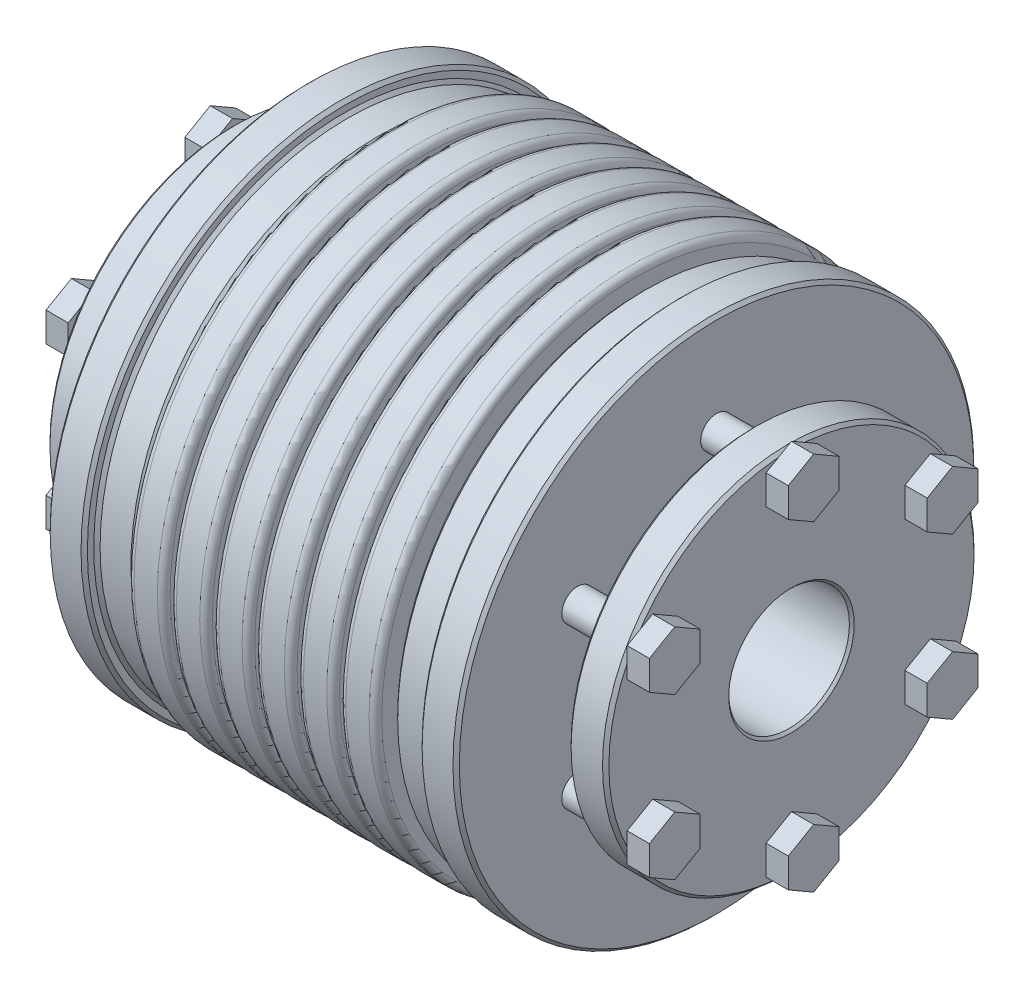
from build123d import *

# Parameters (mm, degrees)
SKETCH1_R                      = 41
BOSS_EXTRUDE1_DEPTH            = 44
SKETCH2_R                      = 9.5
CUT_EXTRUDE1_DEPTH             = 19
CHAMFER1_SIZE                  = 0.381
CUT_EXTRUDE2_REACH             = 46
SKETCH5_R                      = 25.4405
CUT_EXTRUDE2_DIRECTION_2_REACH = 46
SKETCH8_W                      = 1
SKETCH8_H                      = 13.5595
FILLET1_R                      = 1
FILLET2_R                      = 0.25
BOSS_EXTRUDE2_DEPTH            = 3.5
BOSS_EXTRUDE2_2_DEPTH          = 3.5
BOSS_EXTRUDE2_3_DEPTH          = 3.5
BOSS_EXTRUDE2_4_DEPTH          = 3.5
BOSS_EXTRUDE2_5_DEPTH          = 3.5
BOSS_EXTRUDE2_6_DEPTH          = 3.5
SKETCH11_R                     = 2.5
BOSS_EXTRUDE3_DEPTH            = 15.295142
CHAMFER2_SIZE                  = 0.5


with BuildPart() as part:
    # Sketch1 → Boss-Extrude1 (new body, symmetric)
    with BuildSketch(Plane(origin=(0, 0, 0), x_dir=(0, 0, -1), z_dir=(1, 0, 0))):
        Circle(SKETCH1_R)
    extrude(amount=BOSS_EXTRUDE1_DEPTH, both=True)

    # Sketch2 → Cut-Extrude1 (cut)
    with BuildSketch(Plane(origin=(44, 0, 0), x_dir=(0, 0, -1), z_dir=(1, 0, 0))):
        Circle(SKETCH2_R)
    cut_extrude1 = extrude(amount=-CUT_EXTRUDE1_DEPTH, mode=Mode.SUBTRACT)

    # Mirror3: Cut-Extrude1 across plane
    add(cut_extrude1.mirror(Plane(origin=(0, 0, 0), x_dir=(0, 0, 1), z_dir=(1, 0, 0))), mode=Mode.SUBTRACT)

    # Chamfer1
    chamfer1_edges = [part.edges().sort_by_distance(p)[0] for p in [
        (-44, 0, 41),
        (44, 0, 41),
        (44, 0, 9.5),
        (-44, 0, 9.5),
    ]]
    chamfer(chamfer1_edges, length=CHAMFER1_SIZE)

    # Cut-Extrude2: up to this face of the body (flat: up to its plane)
    cut_extrude2_end = Plane(part.part.faces().sort_by_distance((-25, 0, 0))[0])
    # Sketch5 → Cut-Extrude2 (cut, up to the picked face)
    with BuildSketch(Plane(origin=(0, 0, 0), x_dir=(0, 0, -1), z_dir=(1, 0, 0)), mode=Mode.PRIVATE) as cut_extrude2_sk1:
        Circle(SKETCH5_R)
    cut_extrude2_tool1 = split(extrude(cut_extrude2_sk1.sketch, amount=-CUT_EXTRUDE2_REACH, mode=Mode.PRIVATE), bisect_by=cut_extrude2_end, keep=Keep.BOTH, mode=Mode.PRIVATE)
    add(cut_extrude2_tool1.solids().sort_by(Axis((0, 0, 0), (-1, 0, 0)))[0], mode=Mode.SUBTRACT)

    # Cut-Extrude2 direction 2: up to this face of the body (flat: up to its plane)
    cut_extrude2_direction_2_end = Plane(part.part.faces().sort_by_distance((25, 0, 0))[0])
    # Sketch5 → Cut-Extrude2 direction 2 (cut, up to the picked face)
    with BuildSketch(Plane(origin=(0, 0, 0), x_dir=(0, 0, -1), z_dir=(1, 0, 0)), mode=Mode.PRIVATE) as cut_extrude2_direction_2_sk1:
        Circle(SKETCH5_R)
    cut_extrude2_direction_2_tool1 = split(extrude(cut_extrude2_direction_2_sk1.sketch, amount=CUT_EXTRUDE2_DIRECTION_2_REACH, mode=Mode.PRIVATE), bisect_by=cut_extrude2_direction_2_end, keep=Keep.BOTH, mode=Mode.PRIVATE)
    add(cut_extrude2_direction_2_tool1.solids().sort_by(Axis((0, 0, 0), (1, 0, 0)))[0], mode=Mode.SUBTRACT)

    # Sketch8 → Cut-Revolve1 (revolve, cut)
    with BuildSketch(Plane(origin=(0, 0, 0), x_dir=(1, 0, 0), z_dir=(0, 1, 0)), mode=Mode.PRIVATE) as cut_revolve1_sk:
        with Locations((0, 34.22025)):
            Rectangle(SKETCH8_W, SKETCH8_H)
        with Locations((6.666666667, 34.22025)):
            Rectangle(SKETCH8_W, SKETCH8_H)
        with Locations((13.333333333, 34.22025)):
            Rectangle(SKETCH8_W, SKETCH8_H)
        with Locations((20, 34.22025)):
            Rectangle(SKETCH8_W, SKETCH8_H)
    cut_revolve1 = revolve(cut_revolve1_sk.sketch.rotate(Axis((0, 0, 0), (1, 0, 0)), 180), axis=Axis((0, 0, 0), (1, 0, 0)), mode=Mode.SUBTRACT)  # turned: the seam where the file's is

    # Mirror2: Cut-Revolve1 across plane
    add(cut_revolve1.mirror(Plane(origin=(0, 0, 0), x_dir=(0, 0, 1), z_dir=(1, 0, 0))), mode=Mode.SUBTRACT)

    # Fillet1
    fillet1_edges = [part.edges().sort_by_distance(p)[0] for p in [
        (-0.5, 0, 41),
        (0.5, 0, 41),
        (19.5, 0, 41),
        (20.5, 0, 41),
        (6.166666667, 0, 41),
        (7.166666667, 0, 41),
        (12.833333333, 0, 41),
        (13.833333333, 0, 41),
        (-20.5, 0, 41),
        (-19.5, 0, 41),
        (-6.166666667, 0, 41),
        (-7.166666667, 0, 41),
        (-12.833333333, 0, 41),
        (-13.833333333, 0, 41),
    ]]
    fillet(fillet1_edges, radius=FILLET1_R)

    # Fillet2
    fillet2_edges = [part.edges().sort_by_distance(p)[0] for p in [
        (0.5, 0, -27.4405),
        (-0.5, 0, -27.4405),
        (20.5, 0, -27.4405),
        (19.5, 0, -27.4405),
        (7.166666667, 0, -27.4405),
        (6.166666667, 0, -27.4405),
        (13.833333333, 0, -27.4405),
        (12.833333333, 0, -27.4405),
        (-20.5, 0, -27.4405),
        (-19.5, 0, -27.4405),
        (-6.166666667, 0, -27.4405),
        (-7.166666667, 0, -27.4405),
        (-12.833333333, 0, -27.4405),
        (-13.833333333, 0, -27.4405),
    ]]
    fillet(fillet2_edges, radius=FILLET2_R)

    # Sketch9 → Cut-Revolve2 (revolve, cut)
    with BuildSketch(Plane.XY, mode=Mode.PRIVATE) as cut_revolve2_sk:
        Polygon((20.5, 39), (26.352429211, 39), (26.352429211, 41), (32.204858423, 41), (32.204858423, 20.218058827), (38.057287634, 21.25), (38.057287634, 29.25), (44, 29.25), (44, 46), (20.5, 46), align=None)
        Polygon((-20.5, 46), (-20.5, 39), (-26.352429211, 39), (-26.352429211, 41), (-32.204858423, 41), (-32.204858423, 20.218058827), (-38.057287634, 21.25), (-38.057287634, 29.25), (-44, 29.25), (-44, 46), align=None)
    revolve(cut_revolve2_sk.sketch.rotate(Axis((44, 0, 0), (-1, 0, 0)), 270), axis=Axis((44, 0, 0), (-1, 0, 0)), mode=Mode.SUBTRACT)  # turned: the seam where the file's is

    # Chamfer2
    chamfer2_edges = [part.edges().sort_by_distance(p)[0] for p in [
        (20.5, 0, -39),
        (26.352429211, 0, -39),
        (26.352429211, 0, 41),
        (32.204858423, 0, 41),
        (38.057287634, 0, -29.25),
        (44, 0, -29.25),
        (-38.057287634, 0, -29.25),
        (-44, 0, -29.25),
        (-20.5, 0, -39),
        (-26.352429211, 0, -39),
        (-26.352429211, 0, 41),
        (-32.204858423, 0, 41),
    ]]
    chamfer(chamfer2_edges, length=CHAMFER2_SIZE)


with BuildPart() as body_2:
    # Sketch10 → Boss-Extrude2 (new body)
    with BuildSketch(Plane(origin=(44, 0, 0), x_dir=(0, 0, -1), z_dir=(1, 0, 0))):
        Polygon((17.867141446, 10.315598923), (21.867141446, 8.006197846), (25.867141446, 10.315598923), (25.867141446, 14.934401077), (21.867141446, 17.243802154), (17.867141446, 14.934401077), align=None)
    extrude(amount=BOSS_EXTRUDE2_DEPTH)


with BuildPart() as body_3:
    # Sketch10 → Boss-Extrude2 2 (new body)
    with BuildSketch(Plane(origin=(44, 0, 0), x_dir=(0, 0, -1), z_dir=(1, 0, 0))):
        Polygon((0, 20.631197846), (4, 22.940598923), (4, 27.559401077), (0, 29.868802154), (-4, 27.559401077), (-4, 22.940598923), align=None)
    extrude(amount=BOSS_EXTRUDE2_2_DEPTH)


    add(body_2.part)  # Boss-Extrude3 merges body 2


with BuildPart() as body_4:
    # Sketch10 → Boss-Extrude2 3 (new body)
    with BuildSketch(Plane(origin=(44, 0, 0), x_dir=(0, 0, -1), z_dir=(1, 0, 0))):
        Polygon((17.867141446, -10.315598923), (17.867141446, -14.934401077), (21.867141446, -17.243802154), (25.867141446, -14.934401077), (25.867141446, -10.315598923), (21.867141446, -8.006197846), align=None)
    extrude(amount=BOSS_EXTRUDE2_3_DEPTH)


with BuildPart() as body_5:
    # Sketch10 → Boss-Extrude2 4 (new body)
    with BuildSketch(Plane(origin=(44, 0, 0), x_dir=(0, 0, -1), z_dir=(1, 0, 0))):
        Polygon((0, -20.631197846), (-4, -22.940598923), (-4, -27.559401077), (0, -29.868802154), (4, -27.559401077), (4, -22.940598923), align=None)
    extrude(amount=BOSS_EXTRUDE2_4_DEPTH)


with BuildPart() as body_6:
    # Sketch10 → Boss-Extrude2 5 (new body)
    with BuildSketch(Plane(origin=(44, 0, 0), x_dir=(0, 0, -1), z_dir=(1, 0, 0))):
        Polygon((-17.867141446, -10.315598923), (-21.867141446, -8.006197846), (-25.867141446, -10.315598923), (-25.867141446, -14.934401077), (-21.867141446, -17.243802154), (-17.867141446, -14.934401077), align=None)
    extrude(amount=BOSS_EXTRUDE2_5_DEPTH)


with BuildPart() as body_7:
    # Sketch10 → Boss-Extrude2 6 (new body)
    with BuildSketch(Plane(origin=(44, 0, 0), x_dir=(0, 0, -1), z_dir=(1, 0, 0))):
        Polygon((-17.867141446, 10.315598923), (-17.867141446, 14.934401077), (-21.867141446, 17.243802154), (-25.867141446, 14.934401077), (-25.867141446, 10.315598923), (-21.867141446, 8.006197846), align=None)
    extrude(amount=BOSS_EXTRUDE2_6_DEPTH)


with BuildPart() as body_3_1:
    add(body_3.part)

    add(body_4.part)  # Boss-Extrude3 merges body 4

    add(body_5.part)  # Boss-Extrude3 merges body 5

    add(body_6.part)  # Boss-Extrude3 merges body 6

    add(body_7.part)  # Boss-Extrude3 merges body 7
    # Sketch11 → Boss-Extrude3 (add)
    with BuildSketch(Plane(origin=(47.5, 0, 0), x_dir=(0, 0, -1), z_dir=(1, 0, 0))):
        with Locations((0, 25.25)):
            Circle(SKETCH11_R)
        with Locations((21.867141446, 12.625)):
            Circle(SKETCH11_R)
        with Locations((21.867141446, -12.625)):
            Circle(SKETCH11_R)
        with Locations((0, -25.25)):
            Circle(SKETCH11_R)
        with Locations((-21.867141446, -12.625)):
            Circle(SKETCH11_R)
        with Locations((-21.867141446, 12.625)):
            Circle(SKETCH11_R)
    extrude(amount=-BOSS_EXTRUDE3_DEPTH)


with BuildPart() as body_3_2:
    # Mirror5: mirrored copy
    add(body_3_1.part.mirror(Plane(origin=(0, 0, 0), x_dir=(0, 0, 1), z_dir=(1, 0, 0))))


solid = Compound([part.part, body_3_1.part, body_3_2.part])
